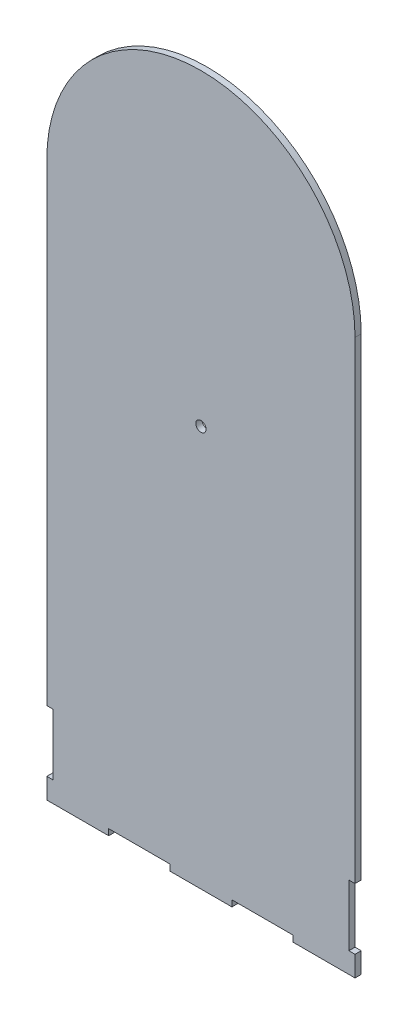
from build123d import *

# Parameters (mm, degrees)
SKETCH1_R           = 2.5
BOSS_EXTRUDE1_DEPTH = 3


with BuildPart() as part:
    # Sketch1 → Boss-Extrude1 (new body)
    with BuildSketch(Plane.XY):
        with BuildLine():
            Line((59.9, 0), (90.1, 0))
            Line((90.1, 0), (90.1, 3))
            Line((90.1, 3), (119.9, 3))
            Line((119.9, 3), (119.9, 0))
            Line((119.9, 0), (150, 0))
            Line((150, 0), (150, 10))
            Line((150, 10), (147, 10))
            Line((147, 10), (147, 39.8))
            Line((147, 39.8), (150, 39.8))
            Line((150, 39.8), (150, 270))
            ThreePointArc((150, 270), (75, 345), (0, 270))
            Line((0, 270), (0, 39.8))
            Line((0, 39.8), (3, 39.8))
            Line((3, 39.8), (3, 10))
            Line((3, 10), (0, 10))
            Line((0, 10), (0, 0))
            Line((0, 0), (30.1, 0))
            Line((30.1, 0), (30.1, 3))
            Line((30.1, 3), (59.9, 3))
            Line((59.9, 3), (59.9, 0))
        make_face()
        with Locations((75, 195)):
            Circle(SKETCH1_R, mode=Mode.SUBTRACT)
    extrude(amount=BOSS_EXTRUDE1_DEPTH)


solid = part.part
